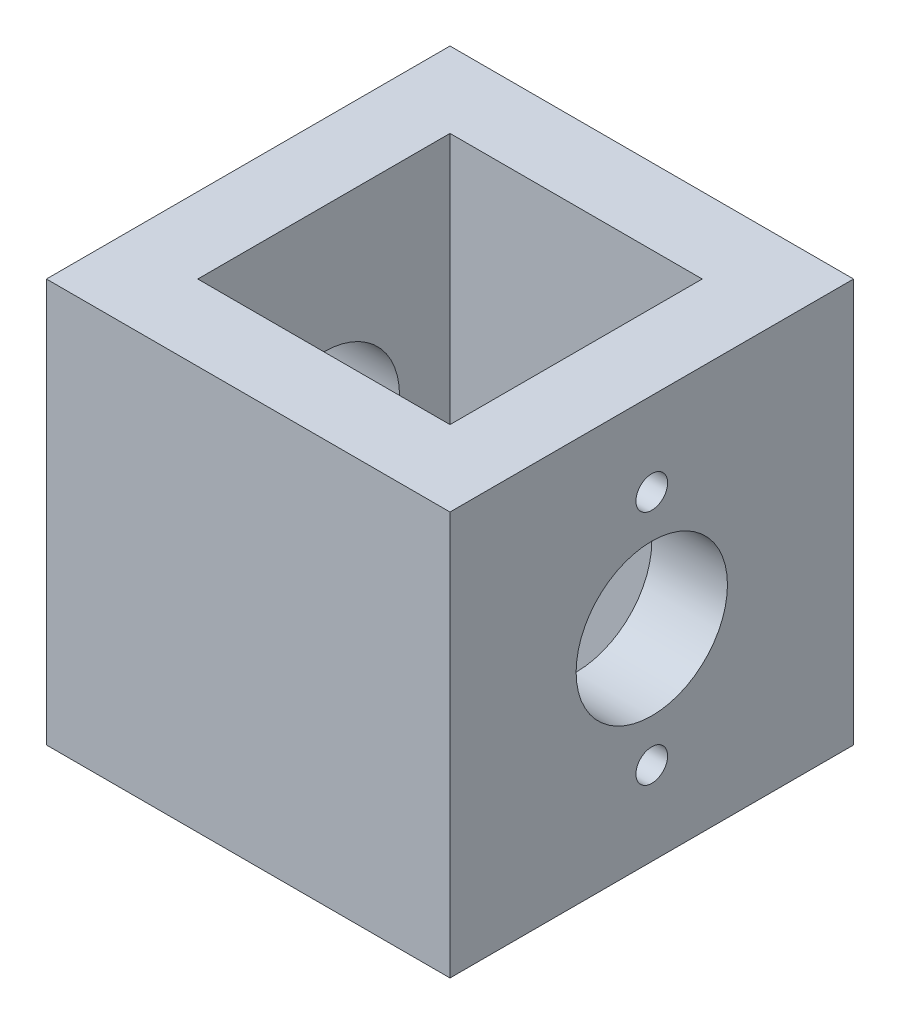
from build123d import *

# Parameters (mm, degrees)
SKETCH1_W                     = 25.4
SKETCH1_H                     = 25.4
BOSS_EXTRUDE1_DEPTH           = 25.4
SKETCH2_W                     = 15.875
SKETCH2_H                     = 15.875
CUT_EXTRUDE1_DEPTH            = 26.4
TAP_DRILL_FOR_4_40_TAP1_D     = 2.2606
TAP_DRILL_FOR_4_40_TAP1_DEPTH = 10.7188
TAP_DRILL_FOR_4_40_TAP1_TIP   = 0.679152758
F_3_8_0_375_DIAMETER_HOLE1_D  = 9.525
TAP_DRILL_FOR_3_48_TAP1_D     = 1.9939
TAP_DRILL_FOR_3_48_TAP1_DEPTH = 4.7625


with BuildPart() as part:
    # Sketch1 → Boss-Extrude1 (new body)
    with BuildSketch(Plane(origin=(0, 0, 0), x_dir=(1, 0, 0), z_dir=(0, 1, 0))):
        with Locations((12.7, 12.7)):
            Rectangle(SKETCH1_W, SKETCH1_H)
    extrude(amount=BOSS_EXTRUDE1_DEPTH)

    # Sketch2 → Cut-Extrude1 (cut, through all)
    with BuildSketch(Plane(origin=(0, 25.4, 0), x_dir=(1, 0, 0), z_dir=(0, 1, 0))):
        with Locations((12.7, 12.7)):
            Rectangle(SKETCH2_W, SKETCH2_H)
    extrude(amount=-CUT_EXTRUDE1_DEPTH, mode=Mode.SUBTRACT)

    # Tap Drill for #4-40 Tap1
    with Locations(Plane(origin=(0, 0, 0), x_dir=(-1, 0, 0), z_dir=(0, -1, 0))):
        with Locations((-2.54, 2.54), (-22.86, 2.54), (-22.86, 22.86), (-2.54, 22.86)):
            Hole(TAP_DRILL_FOR_4_40_TAP1_D / 2, depth=TAP_DRILL_FOR_4_40_TAP1_DEPTH)
            with Locations((0, 0, -(TAP_DRILL_FOR_4_40_TAP1_DEPTH + TAP_DRILL_FOR_4_40_TAP1_TIP / 2))):  # 118° drill point
                Cone(0, TAP_DRILL_FOR_4_40_TAP1_D / 2, TAP_DRILL_FOR_4_40_TAP1_TIP, mode=Mode.SUBTRACT)

    # 3/8 (0.375) Diameter Hole1 (through all)
    with Locations(Plane(origin=(25.4, 0, 0), x_dir=(0, 0, -1), z_dir=(1, 0, 0))):
        with Locations((12.7, 12.7)):
            Hole(F_3_8_0_375_DIAMETER_HOLE1_D / 2)

    # Tap Drill for #3-48 Tap1
    with Locations(Plane(origin=(25.4, 0, 0), x_dir=(0, 0, -1), z_dir=(1, 0, 0))):
        with Locations((12.7, 20.1422), (12.7, 5.2578)):
            Hole(TAP_DRILL_FOR_3_48_TAP1_D / 2, depth=TAP_DRILL_FOR_3_48_TAP1_DEPTH)


solid = part.part
